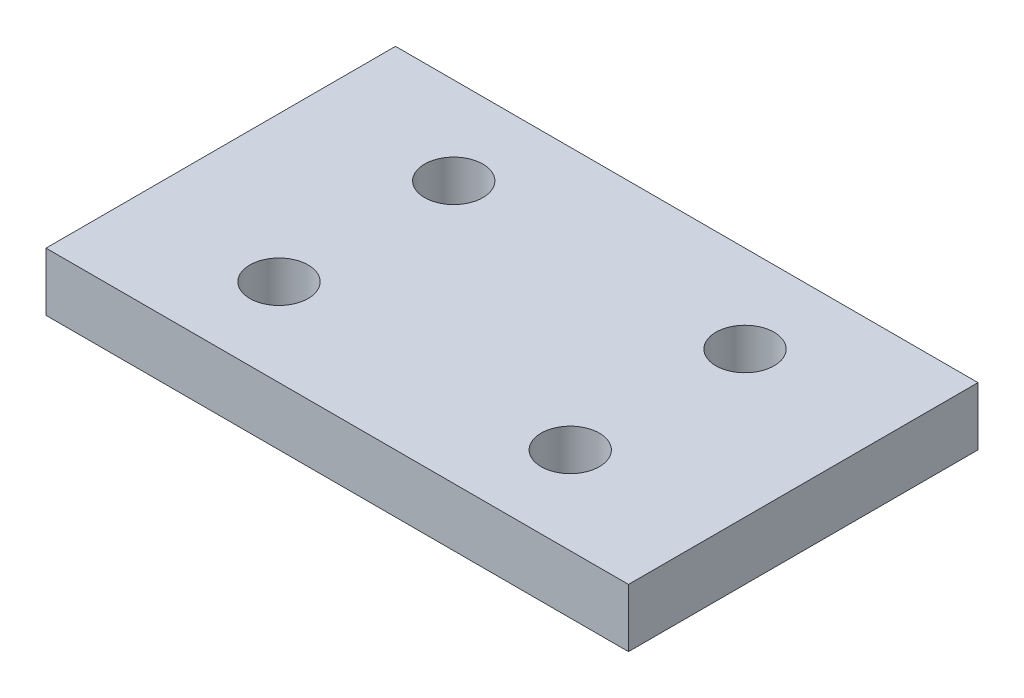
from build123d import *

# Parameters (mm, degrees)
SKETCH_1_W          = 100
SKETCH_1_H          = 60
EXTRUDE_1_DEPTH     = 10
SKETCH_2_R          = 5
CUT_EXTRUDE_1_DEPTH = 11


with BuildPart() as part:
    # Эскиз1 → Бобышка-Вытянуть1 (new body)
    with BuildSketch(Plane(origin=(0, 0, 0), x_dir=(1, 0, 0), z_dir=(0, 1, 0))):
        with Locations((50, 30)):
            Rectangle(SKETCH_1_W, SKETCH_1_H)
    extrude(amount=EXTRUDE_1_DEPTH)

    # Эскиз2 → Вырез-Вытянуть1 (cut, through all)
    with BuildSketch(Plane(origin=(0, 10, 0), x_dir=(1, 0, 0), z_dir=(0, 1, 0))):
        with Locations((25, 15)):
            Circle(SKETCH_2_R)
        with Locations((75, 15)):
            Circle(SKETCH_2_R)
        with Locations((25, 45)):
            Circle(SKETCH_2_R)
        with Locations((75, 45)):
            Circle(SKETCH_2_R)
    extrude(amount=-CUT_EXTRUDE_1_DEPTH, mode=Mode.SUBTRACT)


solid = part.part
